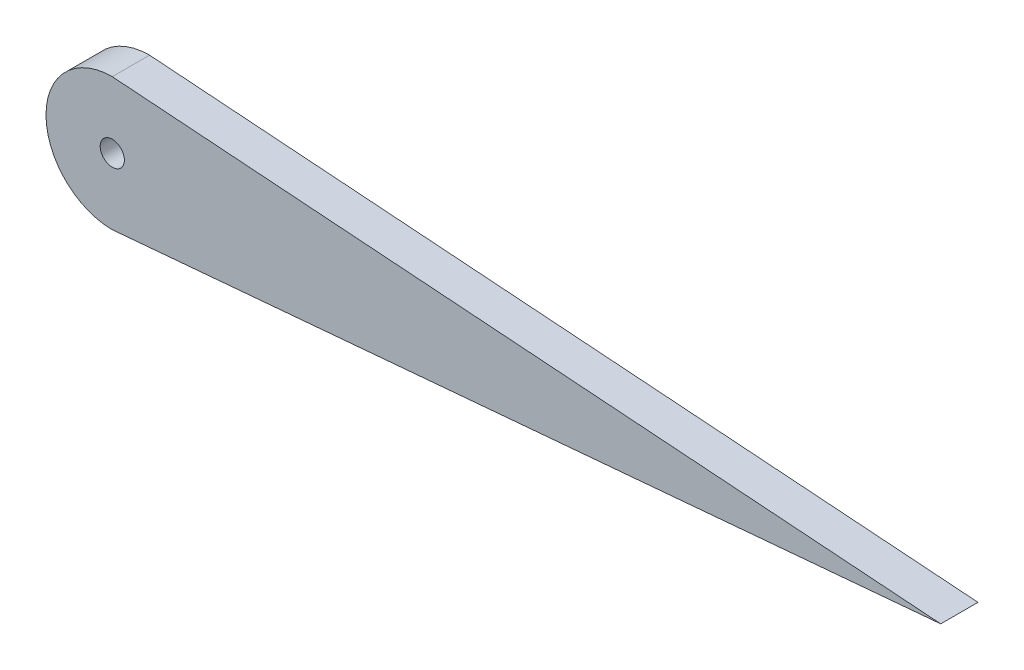
from build123d import *

# Parameters (mm, degrees)
SKETCH1_R           = 0.742804179
BOSS_EXTRUDE1_DEPTH = 2.286


with BuildPart() as part:
    # Sketch1 → Boss-Extrude1 (new body)
    with BuildSketch(Plane.XY):
        with BuildLine():
            Line((0.582241466, 4.022075444), (0, 4.064))
            ThreePointArc((0, 4.064), (-4.064, 0), (0, -4.064))
            Line((0, -4.064), (0.709764944, -4.001540919))
            Line((0.709764944, -4.001540919), (50.798375651, 0.406240321))
            Line((50.798375651, 0.406240321), (0.582241466, 4.022075444))
        make_face()
        Circle(SKETCH1_R, mode=Mode.SUBTRACT)
    extrude(amount=BOSS_EXTRUDE1_DEPTH)


solid = part.part
